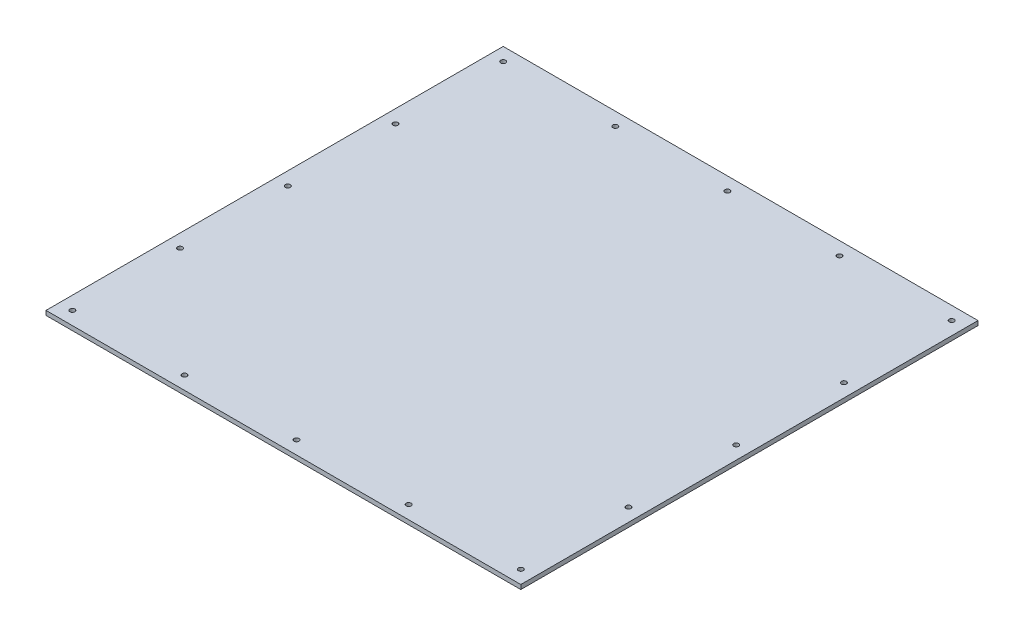
from build123d import *

# Parameters (mm, degrees)
SKETCH2_W           = 685.8
SKETCH2_H           = 660.4
SKETCH2_R           = 3.57
BOSS_EXTRUDE1_DEPTH = 6.35


with BuildPart() as part:
    # Sketch2 → Boss-Extrude1 (new body)
    with BuildSketch(Plane(origin=(0, 0, 0), x_dir=(1, 0, 0), z_dir=(0, 1, 0))):
        with Locations((342.9, -330.2)):
            Rectangle(SKETCH2_W, SKETCH2_H)
        with Locations((19.05, -19.05)):
            Circle(SKETCH2_R, mode=Mode.SUBTRACT)
        with Locations((666.75, -19.05)):
            Circle(SKETCH2_R, mode=Mode.SUBTRACT)
        with Locations((666.75, -641.35)):
            Circle(SKETCH2_R, mode=Mode.SUBTRACT)
        with Locations((19.05, -641.35)):
            Circle(SKETCH2_R, mode=Mode.SUBTRACT)
        with Locations((342.9, -19.05)):
            Circle(SKETCH2_R, mode=Mode.SUBTRACT)
        with Locations((19.05, -330.2)):
            Circle(SKETCH2_R, mode=Mode.SUBTRACT)
        with Locations((342.9, -641.35)):
            Circle(SKETCH2_R, mode=Mode.SUBTRACT)
        with Locations((666.75, -330.2)):
            Circle(SKETCH2_R, mode=Mode.SUBTRACT)
        with Locations((180.975, -19.05)):
            Circle(SKETCH2_R, mode=Mode.SUBTRACT)
        with Locations((504.825, -19.05)):
            Circle(SKETCH2_R, mode=Mode.SUBTRACT)
        with Locations((666.75, -174.625)):
            Circle(SKETCH2_R, mode=Mode.SUBTRACT)
        with Locations((19.05, -174.625)):
            Circle(SKETCH2_R, mode=Mode.SUBTRACT)
        with Locations((19.05, -485.775)):
            Circle(SKETCH2_R, mode=Mode.SUBTRACT)
        with Locations((666.75, -485.775)):
            Circle(SKETCH2_R, mode=Mode.SUBTRACT)
        with Locations((504.825, -641.35)):
            Circle(SKETCH2_R, mode=Mode.SUBTRACT)
        with Locations((180.975, -641.35)):
            Circle(SKETCH2_R, mode=Mode.SUBTRACT)
    extrude(amount=BOSS_EXTRUDE1_DEPTH)


solid = part.part
